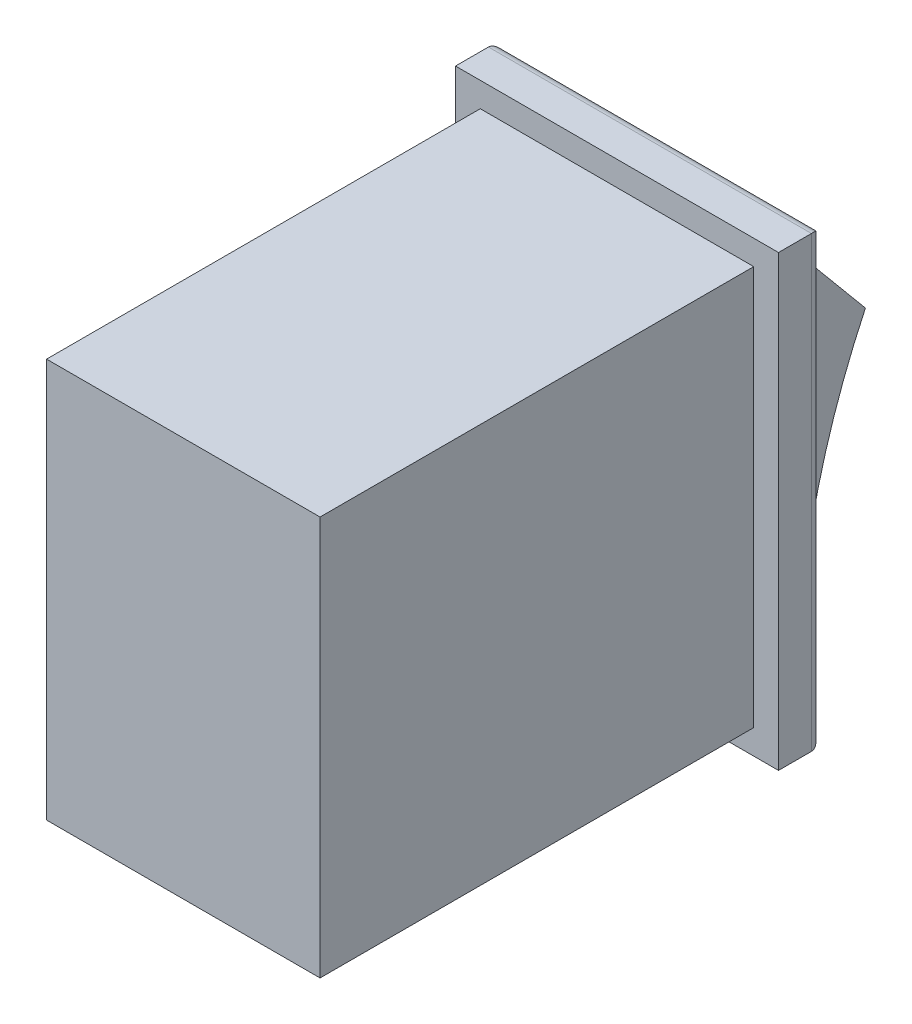
from build123d import *

# Parameters (mm, degrees)
SKETCH1_W      = 12.7
SKETCH1_H      = 18.54
EXTRUDE1_DEPTH = 20.14
SKETCH2_W      = 15
SKETCH2_H      = 20.83
EXTRUDE2_DEPTH = 2.03
FILLET1_R      = 0.5
EXTRUDE3_DEPTH = 12.7


with BuildPart() as part:
    # Sketch1 → Extrude1 (new body)
    with BuildSketch(Plane.XY):
        with Locations((6.35, -9.27)):
            Rectangle(SKETCH1_W, SKETCH1_H)
    extrude(amount=EXTRUDE1_DEPTH)

    # Sketch2 → Extrude2 (add)
    with BuildSketch(Plane(origin=(0, 0, 0), x_dir=(-1, 0, 0), z_dir=(0, 0, -1))):
        with Locations((-6.35, -9.2725)):
            Rectangle(SKETCH2_W, SKETCH2_H)
    extrude(amount=EXTRUDE2_DEPTH)

    # Fillet1
    fillet1_edges = [part.edges().sort_by_distance(p)[0] for p in [
        (6.35, 1.1425, -2.03),
        (13.85, -9.2725, -2.03),
        (-1.15, -9.2725, -2.03),
        (6.35, -19.6875, -2.03),
    ]]
    fillet(fillet1_edges, radius=FILLET1_R)

    # Sketch3 → Extrude3 (add)
    with BuildSketch(Plane.ZY):
        with BuildLine():
            Line((-2.03, -18.257976245), (-2.03, -0.473719642))
            Line((-2.03, -0.473719642), (-5.186140292, -4.258209447))
            ThreePointArc((-5.186140292, -4.258209447), (-2.828813648, -11.082415432), (-2.03, -18.257976245))
        make_face()
    extrude(amount=-EXTRUDE3_DEPTH)


solid = part.part
